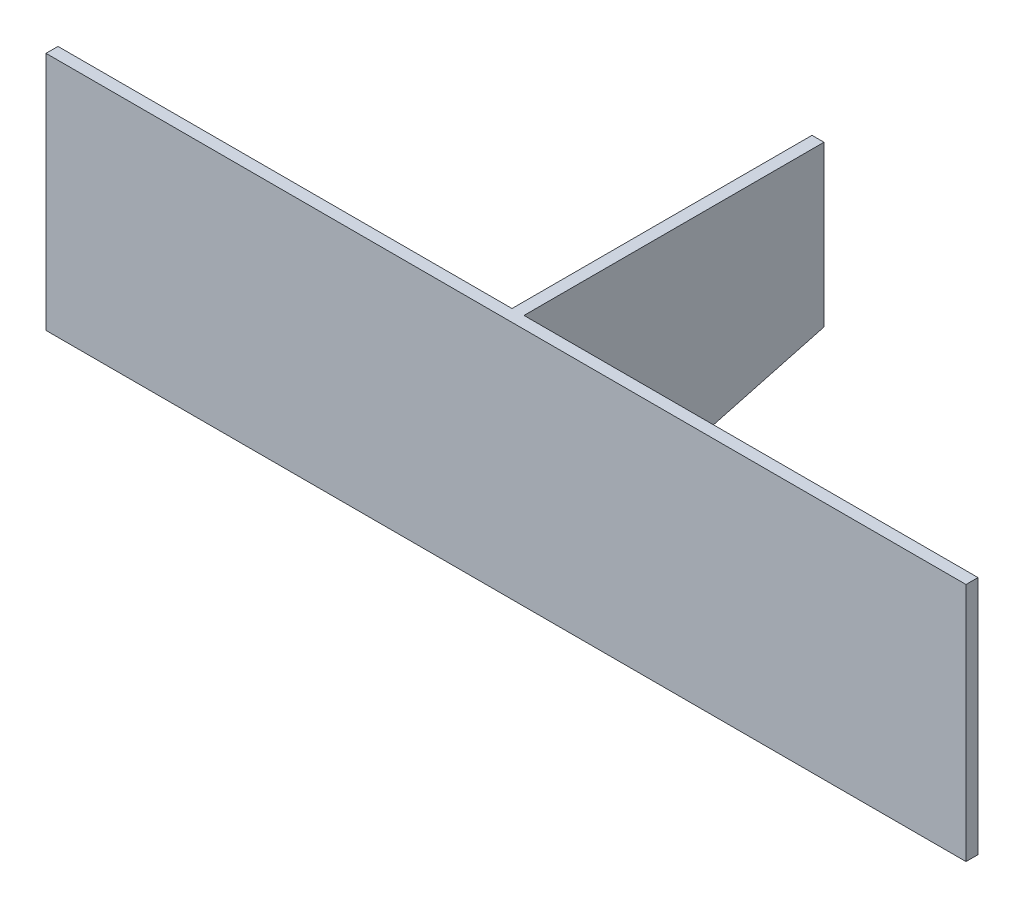
from build123d import *

# Parameters (mm, degrees)
SKETCH1_W           = 230
SKETCH1_H           = 60
BOSS_EXTRUDE1_DEPTH = 3
SKETCH2_W           = 3
SKETCH2_H           = 60
BOSS_EXTRUDE2_DEPTH = 75
CUT_EXTRUDE1_DEPTH  = 75


with BuildPart() as part:
    # Sketch1 → Boss-Extrude1 (new body)
    with BuildSketch(Plane.XY):
        Rectangle(SKETCH1_W, SKETCH1_H)
    extrude(amount=BOSS_EXTRUDE1_DEPTH)

    # Sketch2 → Boss-Extrude2 (add)
    with BuildSketch(Plane(origin=(0, 0, 0), x_dir=(-1, 0, 0), z_dir=(0, 0, -1))):
        Rectangle(SKETCH2_W, SKETCH2_H)
    extrude(amount=BOSS_EXTRUDE2_DEPTH)

    # Sketch3 → Cut-Extrude1 (cut)
    with BuildSketch(Plane(origin=(1.5, 0, 0), x_dir=(0, 0, -1), z_dir=(1, 0, 0))):
        Polygon((75, -10), (0, -30), (75, -30), align=None)
    extrude(amount=-CUT_EXTRUDE1_DEPTH, mode=Mode.SUBTRACT)


solid = part.part
